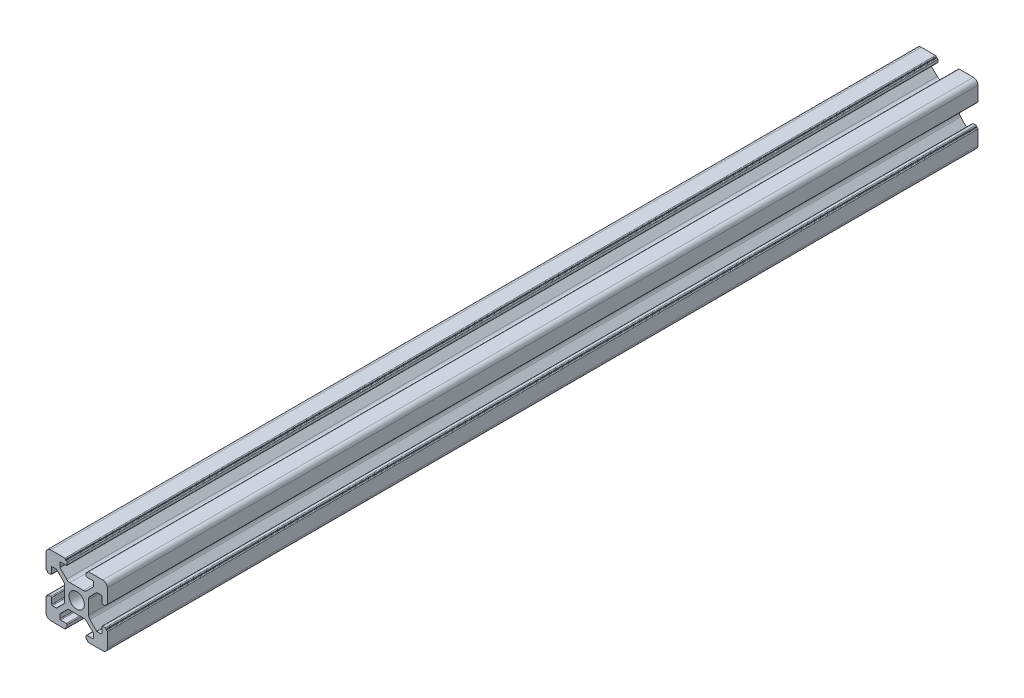
from build123d import *

# Parameters (mm, degrees)
SKETCH_1_R      = 2.5
EXTRUDE_1_DEPTH = 284


with BuildPart() as part:
    # 草图1 → 凸台-拉伸1 (new body)
    with BuildSketch(Plane.XY):
        with BuildLine():
            Line((-8.502261885, -10.002261885), (-3.85, -10.002261885))
            ThreePointArc((-3.85, -10.002261885), (-3.673223305, -9.929038581), (-3.6, -9.752261885))
            Line((-3.6, -9.752261885), (-3.6, -9.502261885))
            Line((-3.6, -9.502261885), (-3.35, -9.502261885))
            ThreePointArc((-3.35, -9.502261885), (-3.173223305, -9.429038581), (-3.1, -9.252261885))
            Line((-3.1, -9.252261885), (-3.1, -8.45))
            ThreePointArc((-3.1, -8.45), (-3.173223305, -8.273223305), (-3.35, -8.2))
            Line((-3.35, -8.2), (-5.25, -8.2))
            ThreePointArc((-5.25, -8.2), (-5.426776695, -8.126776695), (-5.5, -7.95))
            Line((-5.5, -7.95), (-5.5, -6.664213562))
            ThreePointArc((-5.5, -6.664213562), (-5.480969883, -6.568542704), (-5.426776695, -6.487436867))
            Line((-5.426776695, -6.487436867), (-3.278679656, -4.339339828))
            ThreePointArc((-3.278679656, -4.339339828), (-2.792044633, -4.014180701), (-2.218019485, -3.9))
            Line((-2.218019485, -3.9), (2.218019485, -3.9))
            ThreePointArc((2.218019485, -3.9), (2.792044633, -4.014180701), (3.278679656, -4.339339828))
            Line((3.278679656, -4.339339828), (5.426776695, -6.487436867))
            ThreePointArc((5.426776695, -6.487436867), (5.480969883, -6.568542704), (5.5, -6.664213562))
            Line((5.5, -6.664213562), (5.5, -7.95))
            ThreePointArc((5.5, -7.95), (5.426776695, -8.126776695), (5.25, -8.2))
            Line((5.25, -8.2), (3.35, -8.2))
            ThreePointArc((3.35, -8.2), (3.173223305, -8.273223305), (3.1, -8.45))
            Line((3.1, -8.45), (3.1, -9.252261885))
            ThreePointArc((3.1, -9.252261885), (3.173223305, -9.429038581), (3.35, -9.502261885))
            Line((3.35, -9.502261885), (3.6, -9.502261885))
            Line((3.6, -9.502261885), (3.6, -9.752261885))
            ThreePointArc((3.6, -9.752261885), (3.673223305, -9.929038581), (3.85, -10.002261885))
            Line((3.85, -10.002261885), (8.502261885, -10.002261885))
            ThreePointArc((8.502261885, -10.002261885), (9.562922057, -9.562922057), (10.002261885, -8.502261885))
            Line((10.002261885, -8.502261885), (10.002261885, -3.85))
            ThreePointArc((10.002261885, -3.85), (9.929038581, -3.673223305), (9.752261885, -3.6))
            Line((9.752261885, -3.6), (9.502261885, -3.6))
            Line((9.502261885, -3.6), (9.502261885, -3.35))
            ThreePointArc((9.502261885, -3.35), (9.429038581, -3.173223305), (9.252261885, -3.1))
            Line((9.252261885, -3.1), (8.45, -3.1))
            ThreePointArc((8.45, -3.1), (8.273223305, -3.173223305), (8.2, -3.35))
            Line((8.2, -3.35), (8.2, -5.25))
            ThreePointArc((8.2, -5.25), (8.126776695, -5.426776695), (7.95, -5.5))
            Line((7.95, -5.5), (6.664213562, -5.5))
            ThreePointArc((6.664213562, -5.5), (6.568542704, -5.480969883), (6.487436867, -5.426776695))
            Line((6.487436867, -5.426776695), (4.339339828, -3.278679656))
            ThreePointArc((4.339339828, -3.278679656), (4.014180701, -2.792044633), (3.9, -2.218019485))
            Line((3.9, -2.218019485), (3.9, 2.218019485))
            ThreePointArc((3.9, 2.218019485), (4.014180701, 2.792044633), (4.339339828, 3.278679656))
            Line((4.339339828, 3.278679656), (6.487436867, 5.426776695))
            ThreePointArc((6.487436867, 5.426776695), (6.568542704, 5.480969883), (6.664213562, 5.5))
            Line((6.664213562, 5.5), (7.95, 5.5))
            ThreePointArc((7.95, 5.5), (8.126776695, 5.426776695), (8.2, 5.25))
            Line((8.2, 5.25), (8.2, 3.35))
            ThreePointArc((8.2, 3.35), (8.273223305, 3.173223305), (8.45, 3.1))
            Line((8.45, 3.1), (9.252261885, 3.1))
            ThreePointArc((9.252261885, 3.1), (9.429038581, 3.173223305), (9.502261885, 3.35))
            Line((9.502261885, 3.35), (9.502261885, 3.6))
            Line((9.502261885, 3.6), (9.752261885, 3.6))
            ThreePointArc((9.752261885, 3.6), (9.929038581, 3.673223305), (10.002261885, 3.85))
            Line((10.002261885, 3.85), (10.002261885, 8.502261885))
            ThreePointArc((10.002261885, 8.502261885), (9.562922057, 9.562922057), (8.502261885, 10.002261885))
            Line((8.502261885, 10.002261885), (3.85, 10.002261885))
            ThreePointArc((3.85, 10.002261885), (3.673223305, 9.929038581), (3.6, 9.752261885))
            Line((3.6, 9.752261885), (3.6, 9.502261885))
            Line((3.6, 9.502261885), (3.35, 9.502261885))
            ThreePointArc((3.35, 9.502261885), (3.173223305, 9.429038581), (3.1, 9.252261885))
            Line((3.1, 9.252261885), (3.1, 8.45))
            ThreePointArc((3.1, 8.45), (3.173223305, 8.273223305), (3.35, 8.2))
            Line((3.35, 8.2), (5.25, 8.2))
            ThreePointArc((5.25, 8.2), (5.426776695, 8.126776695), (5.5, 7.95))
            Line((5.5, 7.95), (5.5, 6.664213562))
            ThreePointArc((5.5, 6.664213562), (5.480969883, 6.568542704), (5.426776695, 6.487436867))
            Line((5.426776695, 6.487436867), (3.278679656, 4.339339828))
            ThreePointArc((3.278679656, 4.339339828), (2.792044633, 4.014180701), (2.218019485, 3.9))
            Line((2.218019485, 3.9), (-2.218019485, 3.9))
            ThreePointArc((-2.218019485, 3.9), (-2.792044633, 4.014180701), (-3.278679656, 4.339339828))
            Line((-3.278679656, 4.339339828), (-5.426776695, 6.487436867))
            ThreePointArc((-5.426776695, 6.487436867), (-5.480969883, 6.568542704), (-5.5, 6.664213562))
            Line((-5.5, 6.664213562), (-5.5, 7.95))
            ThreePointArc((-5.5, 7.95), (-5.426776695, 8.126776695), (-5.25, 8.2))
            Line((-5.25, 8.2), (-3.35, 8.2))
            ThreePointArc((-3.35, 8.2), (-3.173223305, 8.273223305), (-3.1, 8.45))
            Line((-3.1, 8.45), (-3.1, 9.252261885))
            ThreePointArc((-3.1, 9.252261885), (-3.173223305, 9.429038581), (-3.35, 9.502261885))
            Line((-3.35, 9.502261885), (-3.6, 9.502261885))
            Line((-3.6, 9.502261885), (-3.6, 9.752261885))
            ThreePointArc((-3.6, 9.752261885), (-3.673223305, 9.929038581), (-3.85, 10.002261885))
            Line((-3.85, 10.002261885), (-8.502261885, 10.002261885))
            ThreePointArc((-8.502261885, 10.002261885), (-9.562922057, 9.562922057), (-10.002261885, 8.502261885))
            Line((-10.002261885, 8.502261885), (-10.002261885, 3.85))
            ThreePointArc((-10.002261885, 3.85), (-9.929038581, 3.673223305), (-9.752261885, 3.6))
            Line((-9.752261885, 3.6), (-9.502261885, 3.6))
            Line((-9.502261885, 3.6), (-9.502261885, 3.35))
            ThreePointArc((-9.502261885, 3.35), (-9.429038581, 3.173223305), (-9.252261885, 3.1))
            Line((-9.252261885, 3.1), (-8.45, 3.1))
            ThreePointArc((-8.45, 3.1), (-8.273223305, 3.173223305), (-8.2, 3.35))
            Line((-8.2, 3.35), (-8.2, 5.25))
            ThreePointArc((-8.2, 5.25), (-8.126776695, 5.426776695), (-7.95, 5.5))
            Line((-7.95, 5.5), (-6.664213562, 5.5))
            ThreePointArc((-6.664213562, 5.5), (-6.568542704, 5.480969883), (-6.487436867, 5.426776695))
            Line((-6.487436867, 5.426776695), (-4.339339828, 3.278679656))
            ThreePointArc((-4.339339828, 3.278679656), (-4.014180701, 2.792044633), (-3.9, 2.218019485))
            Line((-3.9, 2.218019485), (-3.9, -2.218019485))
            ThreePointArc((-3.9, -2.218019485), (-4.014180701, -2.792044633), (-4.339339828, -3.278679656))
            Line((-4.339339828, -3.278679656), (-6.487436867, -5.426776695))
            ThreePointArc((-6.487436867, -5.426776695), (-6.568542704, -5.480969883), (-6.664213562, -5.5))
            Line((-6.664213562, -5.5), (-7.95, -5.5))
            ThreePointArc((-7.95, -5.5), (-8.126776695, -5.426776695), (-8.2, -5.25))
            Line((-8.2, -5.25), (-8.2, -3.35))
            ThreePointArc((-8.2, -3.35), (-8.273223305, -3.173223305), (-8.45, -3.1))
            Line((-8.45, -3.1), (-9.252261885, -3.1))
            ThreePointArc((-9.252261885, -3.1), (-9.429038581, -3.173223305), (-9.502261885, -3.35))
            Line((-9.502261885, -3.35), (-9.502261885, -3.6))
            Line((-9.502261885, -3.6), (-9.752261885, -3.6))
            ThreePointArc((-9.752261885, -3.6), (-9.929038581, -3.673223305), (-10.002261885, -3.85))
            Line((-10.002261885, -3.85), (-10.002261885, -8.502261885))
            ThreePointArc((-10.002261885, -8.502261885), (-9.562922057, -9.562922057), (-8.502261885, -10.002261885))
        make_face()
        Circle(SKETCH_1_R, mode=Mode.SUBTRACT)
    extrude(amount=EXTRUDE_1_DEPTH)


solid = part.part
